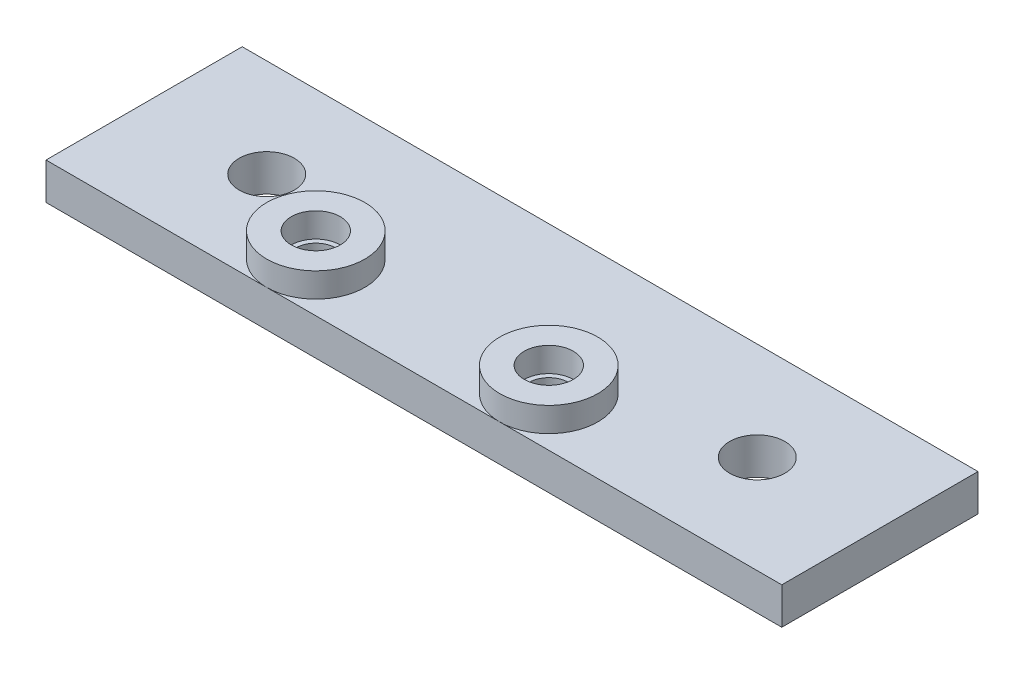
from build123d import *

# Parameters (mm, degrees)
SKETCH1_R             = 4
SKETCH1_R_2           = 2
BOSS_EXTRUDE1_DEPTH   = 2
BOSS_EXTRUDE1_2_DEPTH = 2
SKETCH2_W             = 60
SKETCH2_H             = 16
SKETCH2_R             = 2.25
BOSS_EXTRUDE2_DEPTH   = 3
SKETCH3_R             = 1.6
CUT_EXTRUDE1_DEPTH    = 10


with BuildPart() as part:
    # Sketch1 → Boss-Extrude1 (new body)
    with BuildSketch(Plane(origin=(0, 0, 0), x_dir=(1, 0, 0), z_dir=(0, 1, 0))):
        Circle(SKETCH1_R)
        Circle(SKETCH1_R_2, mode=Mode.SUBTRACT)
    extrude(amount=BOSS_EXTRUDE1_DEPTH)



with BuildPart() as body_2:
    # Sketch1 → Boss-Extrude1 2 (new body)
    with BuildSketch(Plane(origin=(0, 0, 0), x_dir=(1, 0, 0), z_dir=(0, 1, 0))):
        with Locations((19, 0)):
            Circle(SKETCH1_R)
        with Locations((19, 0)):
            Circle(SKETCH1_R_2, mode=Mode.SUBTRACT)
    extrude(amount=BOSS_EXTRUDE1_2_DEPTH)


with BuildPart() as part_1:
    add(part.part)

    add(body_2.part)  # Boss-Extrude2 merges body 2
    # Sketch2 → Boss-Extrude2 (add)
    with BuildSketch(Plane.XZ):
        with Locations((12, -4)):
            Rectangle(SKETCH2_W, SKETCH2_H)
        with Locations((-8, -4)):
            Circle(SKETCH2_R, mode=Mode.SUBTRACT)
        with Locations((32, -4)):
            Circle(SKETCH2_R, mode=Mode.SUBTRACT)
    extrude(amount=BOSS_EXTRUDE2_DEPTH)

    # Sketch3 → Cut-Extrude1 (cut)
    with BuildSketch(Plane(origin=(0, 2, 0), x_dir=(1, 0, 0), z_dir=(0, 1, 0))):
        Circle(SKETCH3_R)
        with Locations((19, 0)):
            Circle(SKETCH3_R)
    extrude(amount=-CUT_EXTRUDE1_DEPTH, mode=Mode.SUBTRACT)


solid = part_1.part
